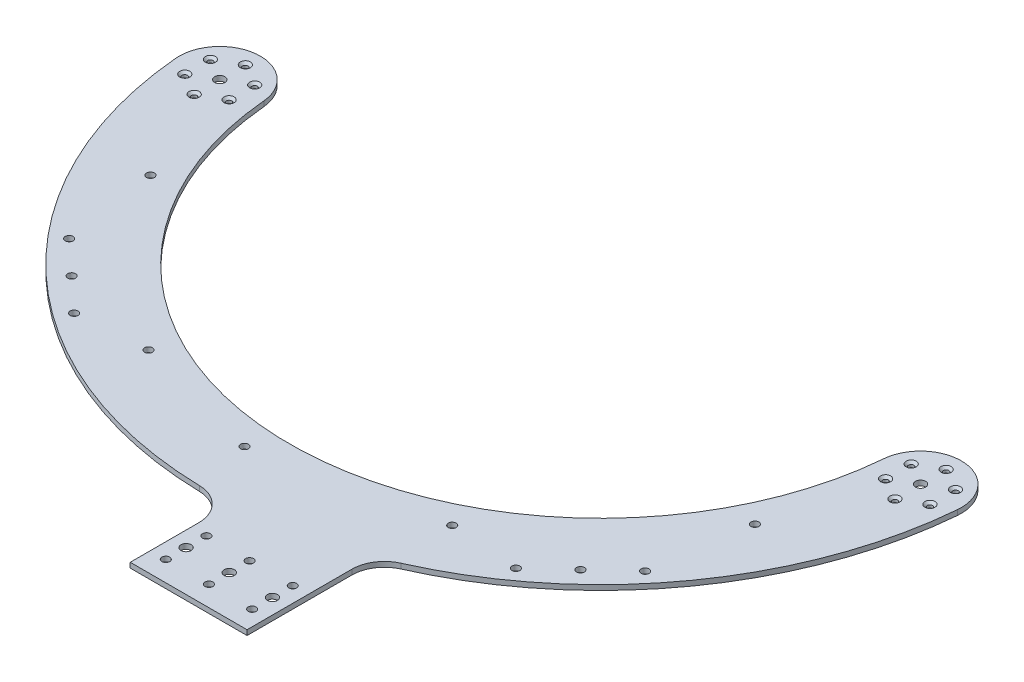
from build123d import *

# Parameters (mm, degrees)
BOSS_EXTRUDE1_DEPTH                             = 3.175
SKETCH2_R                                       = 3.175
CUT_EXTRUDE1_DEPTH                              = 4.175
FILLET1_R                                       = 20.32
CSK_FOR_M3_FLAT_HEAD_MACHINE_SCREW1_D           = 3.4
CSK_FOR_M3_FLAT_HEAD_MACHINE_SCREW1_DEPTH       = 3.175
CSK_FOR_M3_FLAT_HEAD_MACHINE_SCREW1_CSINK_D     = 6.3
CSK_FOR_M3_FLAT_HEAD_MACHINE_SCREW1_CSINK_ANGLE = 90
F_10_0_1935_DIAMETER_HOLE1_D                    = 4.9149
F_10_0_1935_DIAMETER_HOLE1_DEPTH                = 3.175
F_10_0_1935_DIAMETER_HOLE2_D                    = 4.9149
F_10_0_1935_DIAMETER_HOLE2_DEPTH                = 3.175
F_10_0_1935_DIAMETER_HOLE3_D                    = 4.9149
F_10_0_1935_DIAMETER_HOLE3_DEPTH                = 3.175
SKETCH17_R                                      = 3.175
CUT_EXTRUDE2_DEPTH                              = 4.175


with BuildPart() as part:
    # Sketch1 → Boss-Extrude1 (new body)
    with BuildSketch(Plane(origin=(0, 0, 0), x_dir=(1, 0, 0), z_dir=(0, 1, 0))):
        with BuildLine():
            Line((36.5125, 0), (-36.5125, 0))
            Line((-36.5125, 0), (-36.5125, 63.5))
            ThreePointArc((-36.5125, 63.5), (-211.232921163, 122.820712342), (-295.17951094, 287.134870433))
            ThreePointArc((-295.17951094, 287.134870433), (-272.075392256, 314.639773629), (-244.57048906, 291.535654944))
            ThreePointArc((-244.57048906, 291.535654944), (-50.8, 113.883561638), (142.97048906, 291.535654944))
            ThreePointArc((142.97048906, 291.535654944), (170.475392256, 314.639773629), (193.57951094, 287.134870433))
            ThreePointArc((193.57951094, 287.134870433), (144.953596881, 160.556125349), (36.5125, 79.148590487))
            Line((36.5125, 79.148590487), (36.5125, 0))
        make_face()
    extrude(amount=BOSS_EXTRUDE1_DEPTH)

    # Sketch2 → Cut-Extrude1 (cut, through all)
    with BuildSketch(Plane(origin=(0, 3.175, 0), x_dir=(1, 0, 0), z_dir=(0, 1, 0))):
        with Locations((-269.875, 289.335262689)):
            Circle(SKETCH2_R)
        with Locations((168.275, 289.335262689)):
            Circle(SKETCH2_R)
    extrude(amount=-CUT_EXTRUDE1_DEPTH, mode=Mode.SUBTRACT)

    # Fillet1
    fillet1_edges = [part.edges().sort_by_distance(p)[0] for p in [
        (-36.5125, 1.5875, -63.5),
        (36.5125, 1.5875, -79.148590487),
    ]]
    fillet(fillet1_edges, radius=FILLET1_R)

    # CSK for M3 Flat Head Machine Screw1
    with Locations(Plane(origin=(0, 3.175, 0), x_dir=(1, 0, 0), z_dir=(0, 1, 0))):
        with Locations((-269.875, 305.335262689), (168.275, 305.335262689), (182.131406461, 297.335262689), (182.131406461, 281.335262689), (168.275, 273.335262689), (154.418593539, 281.335262689), (154.418593539, 297.335262689), (-256.018593539, 297.335262689), (-256.018593539, 281.335262689), (-269.875, 273.335262689), (-283.731406461, 281.335262689), (-283.731406461, 297.335262689)):
            CounterSinkHole(CSK_FOR_M3_FLAT_HEAD_MACHINE_SCREW1_D / 2, CSK_FOR_M3_FLAT_HEAD_MACHINE_SCREW1_CSINK_D / 2, depth=CSK_FOR_M3_FLAT_HEAD_MACHINE_SCREW1_DEPTH, counter_sink_angle=CSK_FOR_M3_FLAT_HEAD_MACHINE_SCREW1_CSINK_ANGLE)

    # #10 (0.1935) Diameter Hole1
    with Locations(Plane(origin=(0, 3.175, 0), x_dir=(1, 0, 0), z_dir=(0, 1, 0))):
        with Locations((-26.9875, 12.7), (-26.9875, 38.1), (0, 38.1), (0, 12.7), (26.9875, 12.7), (26.9875, 38.1)):
            Hole(F_10_0_1935_DIAMETER_HOLE1_D / 2, depth=F_10_0_1935_DIAMETER_HOLE1_DEPTH)

    # #10 (0.1935) Diameter Hole2
    with Locations(Plane(origin=(0, 3.175, 0), x_dir=(1, 0, 0), z_dir=(0, 1, 0))):
        with Locations((87.3125, 117.294734137), (108.272403388, 136.716708161), (129.232306776, 156.138682184), (-188.9125, 117.294734137), (-209.872403388, 136.716708161), (-230.832306776, 156.138682184)):
            Hole(F_10_0_1935_DIAMETER_HOLE2_D / 2, depth=F_10_0_1935_DIAMETER_HOLE2_DEPTH)

    # #10 (0.1935) Diameter Hole3
    with Locations(Plane(origin=(0, 3.175, 0), x_dir=(1, 0, 0), z_dir=(0, 1, 0))):
        with Locations((-63.5, 98.392247698), (44.141179096, 120.65), (138.157224076, 215.9), (-239.757224076, 215.9), (-145.741179096, 120.65)):
            Hole(F_10_0_1935_DIAMETER_HOLE3_D / 2, depth=F_10_0_1935_DIAMETER_HOLE3_DEPTH)

    # Sketch17 → Cut-Extrude2 (cut, through all)
    with BuildSketch(Plane(origin=(0, 3.175, 0), x_dir=(1, 0, 0), z_dir=(0, 1, 0))):
        with Locations((-26.9875, 25.4)):
            Circle(SKETCH17_R)
        with Locations((0, 25.4)):
            Circle(SKETCH17_R)
        with Locations((26.9875, 25.4)):
            Circle(SKETCH17_R)
    extrude(amount=-CUT_EXTRUDE2_DEPTH, mode=Mode.SUBTRACT)


solid = part.part
